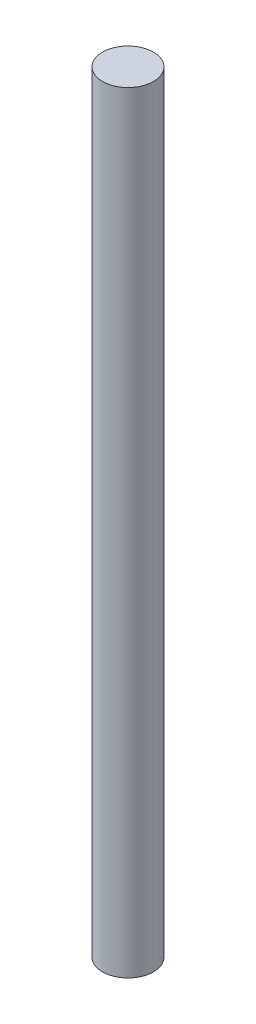
from build123d import *

# Parameters (mm, degrees)
SKETCH1_R           = 2.5
BOSS_EXTRUDE1_DEPTH = 75.7


with BuildPart() as part:
    # Sketch1 → Boss-Extrude1 (new body)
    with BuildSketch(Plane(origin=(0, 0, 0), x_dir=(1, 0, 0), z_dir=(0, 1, 0))):
        Circle(SKETCH1_R)
    extrude(amount=BOSS_EXTRUDE1_DEPTH)


solid = part.part
